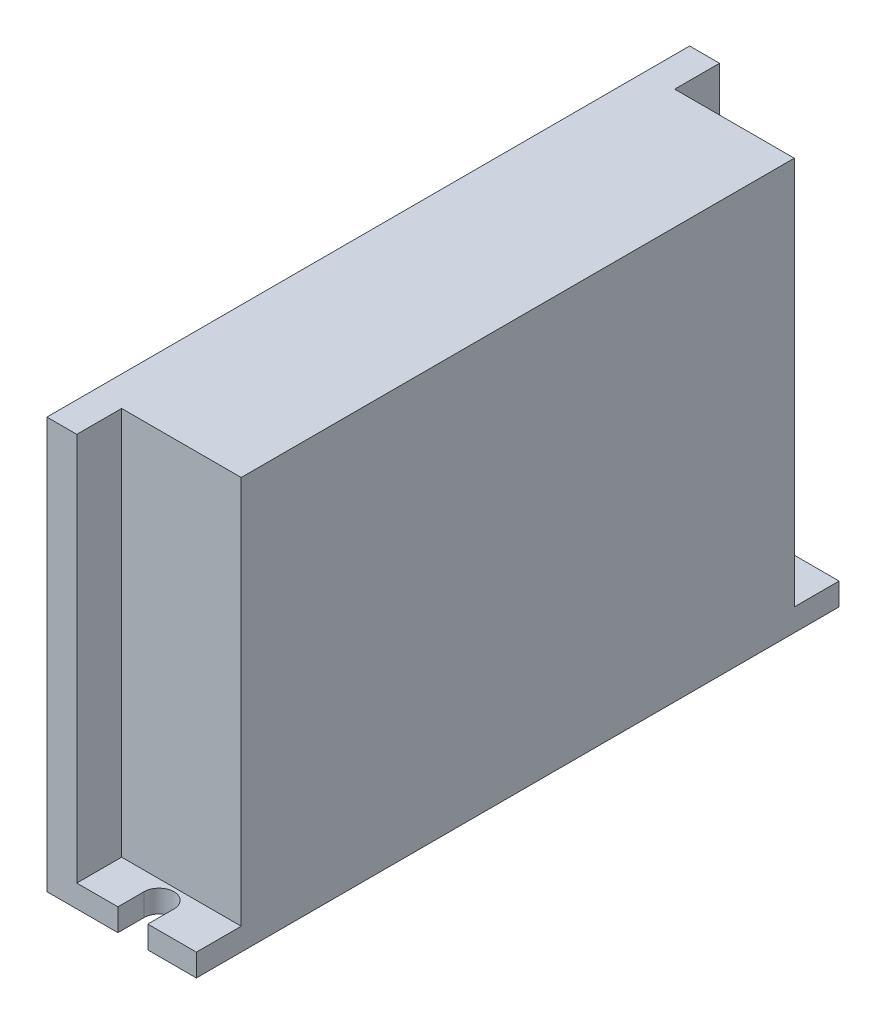
from build123d import *

# Parameters (mm, degrees)
SKETCH1_W           = 20
SKETCH1_H           = 86
BOSS_EXTRUDE1_DEPTH = 3
CUT_EXTRUDE1_DEPTH  = 4
SKETCH3_W           = 4
SKETCH3_H           = 86
BOSS_EXTRUDE2_DEPTH = 52
SKETCH4_W           = 16
SKETCH4_H           = 74
BOSS_EXTRUDE3_DEPTH = 52


with BuildPart() as part:
    # Sketch1 → Boss-Extrude1 (new body)
    with BuildSketch(Plane(origin=(0, 0, 0), x_dir=(1, 0, 0), z_dir=(0, 1, 0))):
        Rectangle(SKETCH1_W, SKETCH1_H)
    extrude(amount=BOSS_EXTRUDE1_DEPTH)

    # Sketch2 → Cut-Extrude1 (cut, through all)
    with BuildSketch(Plane(origin=(0, 3, 0), x_dir=(1, 0, 0), z_dir=(0, 1, 0))):
        with BuildLine():
            Line((-0.5, 39.5), (-0.5, 43))
            Line((-0.5, 43), (3.5, 43))
            Line((3.5, 43), (3.5, 39.5))
            ThreePointArc((3.5, 39.5), (1.5, 37.5), (-0.5, 39.5))
        make_face()
        with BuildLine():
            Line((-0.5, -39.5), (-0.5, -43))
            Line((-0.5, -43), (3.5, -43))
            Line((3.5, -43), (3.5, -39.5))
            ThreePointArc((3.5, -39.5), (1.5, -37.5), (-0.5, -39.5))
        make_face()
    extrude(amount=-CUT_EXTRUDE1_DEPTH, mode=Mode.SUBTRACT)

    # Sketch3 → Boss-Extrude2 (add)
    with BuildSketch(Plane(origin=(0, 3, 0), x_dir=(1, 0, 0), z_dir=(0, 1, 0))):
        with Locations((-8, 0)):
            Rectangle(SKETCH3_W, SKETCH3_H)
    extrude(amount=BOSS_EXTRUDE2_DEPTH)

    # Sketch4 → Boss-Extrude3 (add)
    with BuildSketch(Plane(origin=(0, 3, 0), x_dir=(1, 0, 0), z_dir=(0, 1, 0))):
        with Locations((2, 0)):
            Rectangle(SKETCH4_W, SKETCH4_H)
    extrude(amount=BOSS_EXTRUDE3_DEPTH)


solid = part.part
